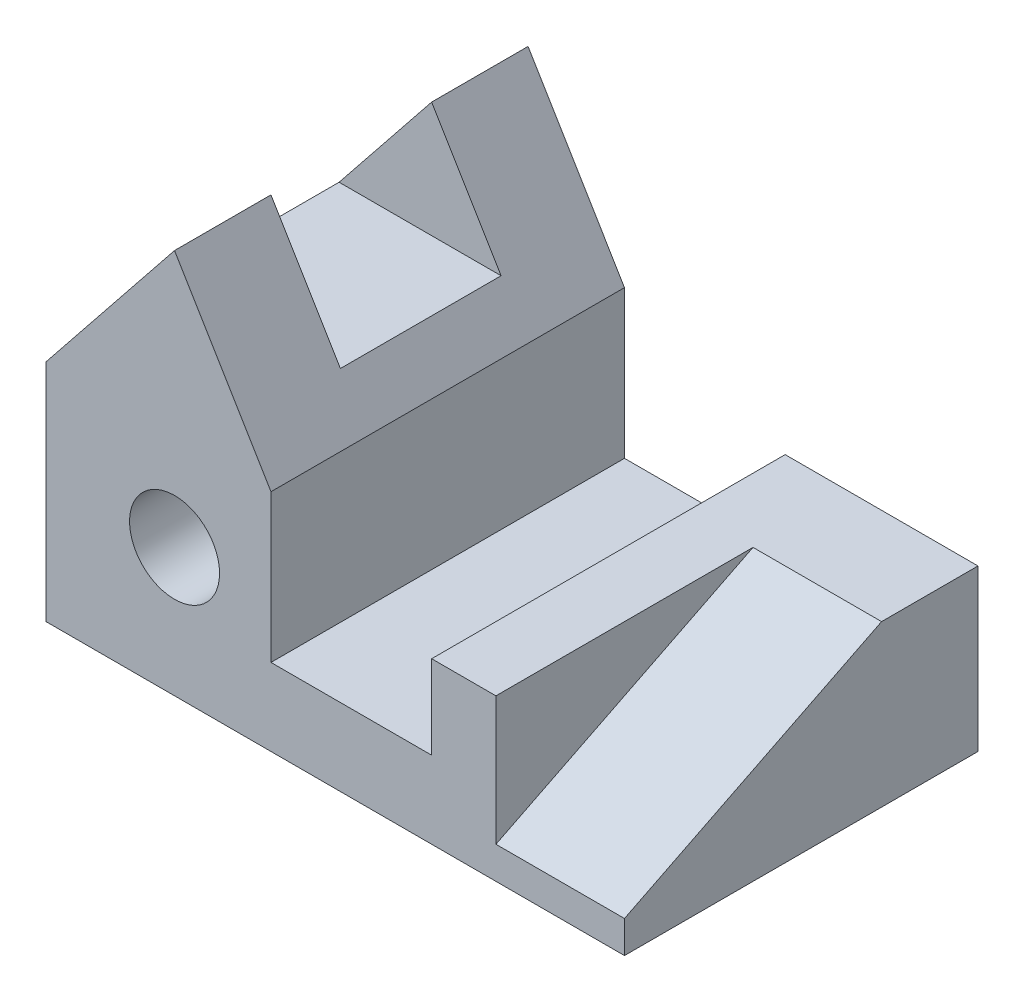
from build123d import *

# Parameters (mm, degrees)
SKETCH2_R               = 7
BOSS_EXTRUDE1_DEPTH     = 55
CUT_EXTRUDE1_DEPTH      = 1
CUT_EXTRUDE1_DEPTH_BACK = 20
SKETCH5_W               = 25
SKETCH5_H               = 18
CUT_EXTRUDE2_DEPTH      = 91


with BuildPart() as part:
    # Sketch2 → Boss-Extrude1 (new body)
    with BuildSketch(Plane.XY):
        Polygon((0, 0), (0, 35), (20, 60), (35, 35), (35, 12), (60, 12), (60, 25), (90, 25), (90, 0), align=None)
        with Locations((20, 20)):
            Circle(SKETCH2_R, mode=Mode.SUBTRACT)
    extrude(amount=BOSS_EXTRUDE1_DEPTH)

    # Sketch3 → Cut-Extrude1 (cut, two sides)
    with BuildSketch(Plane(origin=(90, 0, 0), x_dir=(0, 0, -1), z_dir=(1, 0, 0))) as cut_extrude1_sk:
        Polygon((-203.084488957, -69.042244479), (-55, 5), (-15, 25), (133.084488957, 99.042244479), (-15, 395.211222394), (-351.168977915, 227.126733436), align=None)
    extrude(amount=CUT_EXTRUDE1_DEPTH, mode=Mode.SUBTRACT)
    extrude(cut_extrude1_sk.sketch, amount=-CUT_EXTRUDE1_DEPTH_BACK, mode=Mode.SUBTRACT)

    # Sketch5 → Cut-Extrude2 (cut, through all)
    with BuildSketch(Plane.ZY):
        with Locations((27.5, 51)):
            Rectangle(SKETCH5_W, SKETCH5_H)
    extrude(amount=-CUT_EXTRUDE2_DEPTH, mode=Mode.SUBTRACT)


solid = part.part
